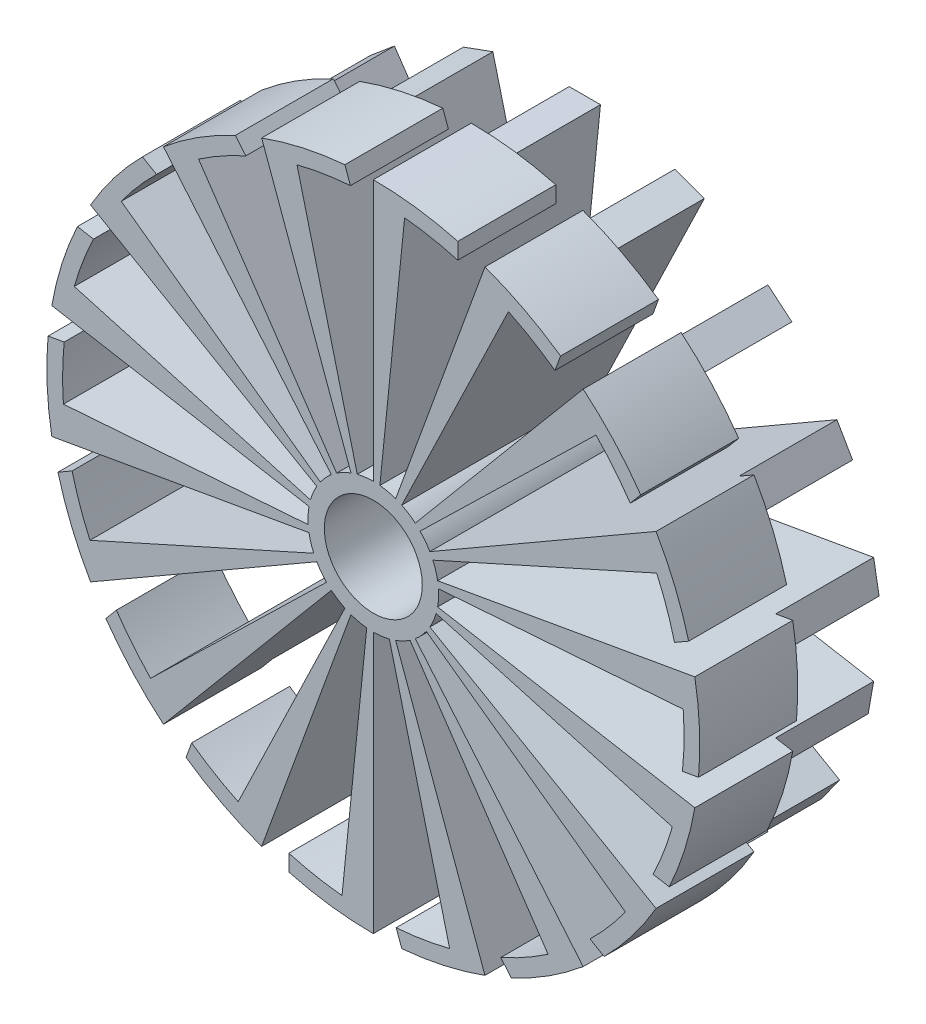
from build123d import *

# Parameters (mm, degrees)
SCHIZZO1_R                      = 20
SCHIZZO1_R_2                    = 15
ESTRUSIONE_ESTRUSIONE1_DEPTH    = 30
ESTRUSIONE_ESTRUSIONE1_2_DEPTH  = 30
ESTRUSIONE_ESTRUSIONE1_3_DEPTH  = 30
ESTRUSIONE_ESTRUSIONE1_4_DEPTH  = 30
ESTRUSIONE_ESTRUSIONE1_5_DEPTH  = 30
ESTRUSIONE_ESTRUSIONE1_6_DEPTH  = 30
ESTRUSIONE_ESTRUSIONE1_7_DEPTH  = 30
ESTRUSIONE_ESTRUSIONE1_8_DEPTH  = 30
ESTRUSIONE_ESTRUSIONE1_9_DEPTH  = 30
ESTRUSIONE_ESTRUSIONE1_10_DEPTH = 30
ESTRUSIONE_ESTRUSIONE1_11_DEPTH = 30
ESTRUSIONE_ESTRUSIONE1_12_DEPTH = 30
ESTRUSIONE_ESTRUSIONE1_13_DEPTH = 30
ESTRUSIONE_ESTRUSIONE1_14_DEPTH = 30
ESTRUSIONE_ESTRUSIONE1_15_DEPTH = 30
ESTRUSIONE_ESTRUSIONE1_16_DEPTH = 30
ESTRUSIONE_ESTRUSIONE1_17_DEPTH = 30
ESTRUSIONE_ESTRUSIONE1_18_DEPTH = 30
ESTRUSIONE_ESTRUSIONE1_19_DEPTH = 30
SCHIZZO1_12_R                   = 15
SCHIZZO1_12_R_2                 = 5
ESTRUSIONE_ESTRUSIONE8_DEPTH    = 30
ESTRUSIONE_ESTRUSIONE9_DEPTH    = 30
ESTRUSIONE_ESTRUSIONE9_2_DEPTH  = 30
ESTRUSIONE_ESTRUSIONE9_3_DEPTH  = 30
ESTRUSIONE_ESTRUSIONE9_4_DEPTH  = 30
ESTRUSIONE_ESTRUSIONE9_5_DEPTH  = 30
ESTRUSIONE_ESTRUSIONE9_6_DEPTH  = 30
ESTRUSIONE_ESTRUSIONE9_7_DEPTH  = 30
ESTRUSIONE_ESTRUSIONE9_8_DEPTH  = 30
ESTRUSIONE_ESTRUSIONE9_9_DEPTH  = 30
ESTRUSIONE_ESTRUSIONE9_10_DEPTH = 30
ESTRUSIONE_ESTRUSIONE9_11_DEPTH = 30
ESTRUSIONE_ESTRUSIONE9_12_DEPTH = 30
ESTRUSIONE_ESTRUSIONE9_13_DEPTH = 30
ESTRUSIONE_ESTRUSIONE9_14_DEPTH = 30
ESTRUSIONE_ESTRUSIONE9_15_DEPTH = 30
ESTRUSIONE_ESTRUSIONE9_16_DEPTH = 30
ESTRUSIONE_ESTRUSIONE9_17_DEPTH = 30
ESTRUSIONE_ESTRUSIONE9_18_DEPTH = 30
SCHIZZO1_14_R                   = 15
ESTRUSIONE_ESTRUSIONE10_DEPTH   = 30
SCHIZZO1_16_R                   = 20
SCHIZZO1_16_R_2                 = 15
ESTRUSIONE_ESTRUSIONE11_DEPTH   = 30
ESTRUSIONE_ESTRUSIONE12_DEPTH   = 30


with BuildPart() as part:
    # Schizzo1 → Estrusione-Estrusione1 (new body)
    with BuildSketch(Plane.XY):
        Circle(SCHIZZO1_R)
        Circle(SCHIZZO1_R_2, mode=Mode.SUBTRACT)
    extrude(amount=ESTRUSIONE_ESTRUSIONE1_DEPTH)



with BuildPart() as body_2:
    # Schizzo1 → Estrusione-Estrusione1 2 (new body)
    with BuildSketch(Plane.XY):
        with BuildLine():
            Line((0, 100), (0, 94.695431044))
            Line((0, 94.695431044), (9.583815163, 94.695431044))
            ThreePointArc((9.583815163, 94.695431044), (17.80059648, 93.499801811), (25.88190451, 91.592582629))
            Line((25.88190451, 91.592582629), (25.88190451, 96.592582629))
            ThreePointArc((25.88190451, 96.592582629), (13.052619222, 99.144486137), (0, 100))
        make_face()
    extrude(amount=ESTRUSIONE_ESTRUSIONE1_2_DEPTH)


with BuildPart() as body_3:
    # Schizzo1 → Estrusione-Estrusione1 3 (new body)
    with BuildSketch(Plane.XY):
        with BuildLine():
            Line((-32.387744898, 88.984597774), (-23.38190451, 92.26245561))
            ThreePointArc((-23.38190451, 92.26245561), (-15.251726458, 93.949236366), (-7.005473558, 94.921006705))
            Line((-7.005473558, 94.921006705), (-8.715574275, 99.619469809))
            ThreePointArc((-8.715574275, 99.619469809), (-21.643961394, 97.629600712), (-34.202014333, 93.969262079))
            Line((-34.202014333, 93.969262079), (-32.387744898, 88.984597774))
        make_face()
    extrude(amount=ESTRUSIONE_ESTRUSIONE1_3_DEPTH)


with BuildPart() as body_4:
    # Schizzo1 → Estrusione-Estrusione1 4 (new body)
    with BuildSketch(Plane.XY):
        with BuildLine():
            Line((34.202014333, 93.969262079), (32.387744898, 88.984597774))
            Line((32.387744898, 88.984597774), (41.393585286, 85.706739939))
            ThreePointArc((41.393585286, 85.706739939), (48.705904774, 81.772911247), (55.647542918, 77.216741325))
            Line((55.647542918, 77.216741325), (57.357643635, 81.915204429))
            ThreePointArc((57.357643635, 81.915204429), (46.174861324, 88.701083318), (34.202014333, 93.969262079))
        make_face()
    extrude(amount=ESTRUSIONE_ESTRUSIONE1_4_DEPTH)


with BuildPart() as body_5:
    # Schizzo1 → Estrusione-Estrusione1 5 (new body)
    with BuildSketch(Plane.XY):
        with BuildLine():
            Line((-60.869049769, 72.54090874), (-53.52742142, 78.70126638))
            ThreePointArc((-53.52742142, 78.70126638), (-46.464466094, 83.067006473), (-39.047888126, 86.800556488))
            Line((-39.047888126, 86.800556488), (-42.261826174, 90.630778704))
            ThreePointArc((-42.261826174, 90.630778704), (-53.729960835, 84.339144581), (-64.278760969, 76.604444312))
            Line((-64.278760969, 76.604444312), (-60.869049769, 72.54090874))
        make_face()
    extrude(amount=ESTRUSIONE_ESTRUSIONE1_5_DEPTH)


with BuildPart() as body_6:
    # Schizzo1 → Estrusione-Estrusione1 6 (new body)
    with BuildSketch(Plane.XY):
        with BuildLine():
            Line((64.278760969, 76.604444312), (60.869049769, 72.54090874))
            Line((60.869049769, 72.54090874), (68.210678119, 66.3805511))
            ThreePointArc((68.210678119, 66.3805511), (73.73656213, 60.183000747), (78.70126638, 53.52742142))
            Line((78.70126638, 53.52742142), (81.915204429, 57.357643635))
            ThreePointArc((81.915204429, 57.357643635), (73.727733681, 67.559020762), (64.278760969, 76.604444312))
        make_face()
    extrude(amount=ESTRUSIONE_ESTRUSIONE1_6_DEPTH)


with BuildPart() as body_7:
    # Schizzo1 → Estrusione-Estrusione1 7 (new body)
    with BuildSketch(Plane.XY):
        with BuildLine():
            Line((-82.008648907, 47.347715522), (-77.216741325, 55.647542918))
            ThreePointArc((-77.216741325, 55.647542918), (-72.072905377, 62.16566966), (-66.3805511, 68.210678119))
            Line((-66.3805511, 68.210678119), (-70.710678119, 70.710678119))
            ThreePointArc((-70.710678119, 70.710678119), (-79.335334029, 60.876142901), (-86.602540378, 50))
            Line((-86.602540378, 50), (-82.008648907, 47.347715522))
        make_face()
    extrude(amount=ESTRUSIONE_ESTRUSIONE1_7_DEPTH)


with BuildPart() as body_8:
    # Schizzo1 → Estrusione-Estrusione1 8 (new body)
    with BuildSketch(Plane.XY):
        with BuildLine():
            Line((86.602540378, 50), (82.008648907, 47.347715522))
            Line((82.008648907, 47.347715522), (86.800556488, 39.047888126))
            ThreePointArc((86.800556488, 39.047888126), (89.873501857, 31.334132151), (92.26245561, 23.38190451))
            Line((92.26245561, 23.38190451), (96.592582629, 25.88190451))
            ThreePointArc((96.592582629, 25.88190451), (92.387953251, 38.268343237), (86.602540378, 50))
        make_face()
    extrude(amount=ESTRUSIONE_ESTRUSIONE1_8_DEPTH)


with BuildPart() as body_9:
    # Schizzo1 → Estrusione-Estrusione1 9 (new body)
    with BuildSketch(Plane.XY):
        with BuildLine():
            Line((-93.256794667, 16.443689034), (-91.592582629, 25.88190451))
            ThreePointArc((-91.592582629, 25.88190451), (-88.988288588, 33.766235619), (-85.706739939, 41.393585286))
            Line((-85.706739939, 41.393585286), (-90.630778704, 42.261826174))
            ThreePointArc((-90.630778704, 42.261826174), (-95.371695075, 30.07057995), (-98.480775301, 17.364817767))
            Line((-98.480775301, 17.364817767), (-93.256794667, 16.443689034))
        make_face()
    extrude(amount=ESTRUSIONE_ESTRUSIONE1_9_DEPTH)


with BuildPart() as body_10:
    # Schizzo1 → Estrusione-Estrusione1 10 (new body)
    with BuildSketch(Plane.XY):
        with BuildLine():
            Line((98.480775301, 17.364817767), (93.256794667, 16.443689034))
            Line((93.256794667, 16.443689034), (94.921006705, 7.005473558))
            ThreePointArc((94.921006705, 7.005473558), (95.170370869, -1.294095226), (94.695431044, -9.583815163))
            Line((94.695431044, -9.583815163), (99.619469809, -8.715574275))
            ThreePointArc((99.619469809, -8.715574275), (99.904822158, 4.361938737), (98.480775301, 17.364817767))
        make_face()
    extrude(amount=ESTRUSIONE_ESTRUSIONE1_10_DEPTH)


with BuildPart() as body_11:
    # Schizzo1 → Estrusione-Estrusione1 11 (new body)
    with BuildSketch(Plane.XY):
        with BuildLine():
            Line((-93.256794667, -16.443689034), (-94.921006705, -7.005473558))
            ThreePointArc((-94.921006705, -7.005473558), (-95.170370869, 1.294095226), (-94.695431044, 9.583815163))
            Line((-94.695431044, 9.583815163), (-99.619469809, 8.715574275))
            ThreePointArc((-99.619469809, 8.715574275), (-99.904822158, -4.361938737), (-98.480775301, -17.364817767))
            Line((-98.480775301, -17.364817767), (-93.256794667, -16.443689034))
        make_face()
    extrude(amount=ESTRUSIONE_ESTRUSIONE1_11_DEPTH)


with BuildPart() as body_12:
    # Schizzo1 → Estrusione-Estrusione1 12 (new body)
    with BuildSketch(Plane.XY):
        with BuildLine():
            Line((98.480775301, -17.364817767), (93.256794667, -16.443689034))
            Line((93.256794667, -16.443689034), (91.592582629, -25.88190451))
            ThreePointArc((91.592582629, -25.88190451), (88.988288588, -33.766235619), (85.706739939, -41.393585286))
            Line((85.706739939, -41.393585286), (90.630778704, -42.261826174))
            ThreePointArc((90.630778704, -42.261826174), (95.371695075, -30.07057995), (98.480775301, -17.364817767))
        make_face()
    extrude(amount=ESTRUSIONE_ESTRUSIONE1_12_DEPTH)


with BuildPart() as body_13:
    # Schizzo1 → Estrusione-Estrusione1 13 (new body)
    with BuildSketch(Plane.XY):
        with BuildLine():
            Line((-82.008648907, -47.347715522), (-86.800556488, -39.047888126))
            ThreePointArc((-86.800556488, -39.047888126), (-89.873501857, -31.334132151), (-92.26245561, -23.38190451))
            Line((-92.26245561, -23.38190451), (-96.592582629, -25.88190451))
            ThreePointArc((-96.592582629, -25.88190451), (-92.387953251, -38.268343237), (-86.602540378, -50))
            Line((-86.602540378, -50), (-82.008648907, -47.347715522))
        make_face()
    extrude(amount=ESTRUSIONE_ESTRUSIONE1_13_DEPTH)


with BuildPart() as body_14:
    # Schizzo1 → Estrusione-Estrusione1 14 (new body)
    with BuildSketch(Plane.XY):
        with BuildLine():
            Line((86.602540378, -50), (82.848647318, -47.832688831))
            Line((82.848647318, -47.832688831), (77.216741325, -55.647542918))
            ThreePointArc((77.216741325, -55.647542918), (72.072905377, -62.16566966), (66.3805511, -68.210678119))
            Line((66.3805511, -68.210678119), (70.710678119, -70.710678119))
            ThreePointArc((70.710678119, -70.710678119), (79.335334029, -60.876142901), (86.602540378, -50))
        make_face()
    extrude(amount=ESTRUSIONE_ESTRUSIONE1_14_DEPTH)


with BuildPart() as body_15:
    # Schizzo1 → Estrusione-Estrusione1 15 (new body)
    with BuildSketch(Plane.XY):
        with BuildLine():
            Line((-60.869049769, -72.54090874), (-68.210678119, -66.3805511))
            ThreePointArc((-68.210678119, -66.3805511), (-73.73656213, -60.183000747), (-78.70126638, -53.52742142))
            Line((-78.70126638, -53.52742142), (-81.915204429, -57.357643635))
            ThreePointArc((-81.915204429, -57.357643635), (-73.727733681, -67.559020762), (-64.278760969, -76.604444312))
            Line((-64.278760969, -76.604444312), (-60.869049769, -72.54090874))
        make_face()
    extrude(amount=ESTRUSIONE_ESTRUSIONE1_15_DEPTH)


with BuildPart() as body_16:
    # Schizzo1 → Estrusione-Estrusione1 16 (new body)
    with BuildSketch(Plane.XY):
        with BuildLine():
            Line((64.278760969, -76.604444312), (60.869049769, -72.54090874))
            Line((60.869049769, -72.54090874), (53.52742142, -78.70126638))
            ThreePointArc((53.52742142, -78.70126638), (46.464466094, -83.067006473), (39.047888126, -86.800556488))
            Line((39.047888126, -86.800556488), (42.261826174, -90.630778704))
            ThreePointArc((42.261826174, -90.630778704), (53.729960835, -84.339144581), (64.278760969, -76.604444312))
        make_face()
    extrude(amount=ESTRUSIONE_ESTRUSIONE1_16_DEPTH)


with BuildPart() as body_17:
    # Schizzo1 → Estrusione-Estrusione1 17 (new body)
    with BuildSketch(Plane.XY):
        with BuildLine():
            Line((-32.387744898, -88.984597774), (-41.393585286, -85.706739939))
            ThreePointArc((-41.393585286, -85.706739939), (-48.705904774, -81.772911247), (-55.647542918, -77.216741325))
            Line((-55.647542918, -77.216741325), (-57.357643635, -81.915204429))
            ThreePointArc((-57.357643635, -81.915204429), (-46.174861324, -88.701083318), (-34.202014333, -93.969262079))
            Line((-34.202014333, -93.969262079), (-32.387744898, -88.984597774))
        make_face()
    extrude(amount=ESTRUSIONE_ESTRUSIONE1_17_DEPTH)


with BuildPart() as body_18:
    # Schizzo1 → Estrusione-Estrusione1 18 (new body)
    with BuildSketch(Plane.XY):
        with BuildLine():
            Line((34.202014333, -93.969262079), (32.387744898, -88.984597774))
            Line((32.387744898, -88.984597774), (23.38190451, -92.26245561))
            ThreePointArc((23.38190451, -92.26245561), (15.251726458, -93.949236366), (7.005473558, -94.921006705))
            Line((7.005473558, -94.921006705), (8.715574275, -99.619469809))
            ThreePointArc((8.715574275, -99.619469809), (21.643961394, -97.629600712), (34.202014333, -93.969262079))
        make_face()
    extrude(amount=ESTRUSIONE_ESTRUSIONE1_18_DEPTH)


with BuildPart() as body_19:
    # Schizzo1 → Estrusione-Estrusione1 19 (new body)
    with BuildSketch(Plane.XY):
        with BuildLine():
            Line((0, -94.695431044), (-9.583815163, -94.695431044))
            ThreePointArc((-9.583815163, -94.695431044), (-17.80059648, -93.499801811), (-25.88190451, -91.592582629))
            Line((-25.88190451, -91.592582629), (-25.88190451, -96.592582629))
            ThreePointArc((-25.88190451, -96.592582629), (-13.052619222, -99.144486137), (0, -100))
            Line((0, -100), (0, -94.695431044))
        make_face()
    extrude(amount=ESTRUSIONE_ESTRUSIONE1_19_DEPTH)


with BuildPart() as body_20:
    # Schizzo1_12 → Estrusione-Estrusione8 (new body)
    with BuildSketch(Plane.XY):
        Circle(SCHIZZO1_12_R)
        Circle(SCHIZZO1_12_R_2, mode=Mode.SUBTRACT)
    extrude(amount=-ESTRUSIONE_ESTRUSIONE8_DEPTH)



with BuildPart() as body_21:
    # Schizzo1_13 → Estrusione-Estrusione9 (new body)
    with BuildSketch(Plane.XY):
        with BuildLine():
            Line((0, 94.695431044), (0, 20))
            ThreePointArc((0, 20), (1.008205442, 19.97457188), (2.013847207, 19.898352179))
            Line((2.013847207, 19.898352179), (9.583815163, 94.695431044))
            Line((9.583815163, 94.695431044), (0, 94.695431044))
        make_face()
    extrude(amount=-ESTRUSIONE_ESTRUSIONE9_DEPTH)


with BuildPart() as body_22:
    # Schizzo1_13 → Estrusione-Estrusione9 2 (new body)
    with BuildSketch(Plane.XY):
        with BuildLine():
            ThreePointArc((-6.840402867, 18.793852416), (-5.884302723, 19.114784369), (-4.913239904, 19.387111018))
            Line((-4.913239904, 19.387111018), (-23.38190451, 92.26245561))
            Line((-23.38190451, 92.26245561), (-32.387744898, 88.984597774))
            Line((-32.387744898, 88.984597774), (-6.840402867, 18.793852416))
        make_face()
    extrude(amount=-ESTRUSIONE_ESTRUSIONE9_2_DEPTH)


with BuildPart() as body_23:
    # Schizzo1_13 → Estrusione-Estrusione9 3 (new body)
    with BuildSketch(Plane.XY):
        with BuildLine():
            Line((32.387744898, 88.984597774), (6.840402867, 18.793852416))
            ThreePointArc((6.840402867, 18.793852416), (7.779109151, 18.425131229), (8.698034624, 18.009558398))
            Line((8.698034624, 18.009558398), (41.393585286, 85.706739939))
            Line((41.393585286, 85.706739939), (32.387744898, 88.984597774))
        make_face()
    extrude(amount=-ESTRUSIONE_ESTRUSIONE9_3_DEPTH)


with BuildPart() as body_24:
    # Schizzo1_13 → Estrusione-Estrusione9 4 (new body)
    with BuildSketch(Plane.XY):
        with BuildLine():
            ThreePointArc((-12.855752194, 15.320888862), (-12.067077137, 15.949471758), (-11.247717771, 16.537498146))
            Line((-11.247717771, 16.537498146), (-53.52742142, 78.70126638))
            Line((-53.52742142, 78.70126638), (-60.869049769, 72.54090874))
            Line((-60.869049769, 72.54090874), (-12.855752194, 15.320888862))
        make_face()
    extrude(amount=-ESTRUSIONE_ESTRUSIONE9_4_DEPTH)


with BuildPart() as body_25:
    # Schizzo1_13 → Estrusione-Estrusione9 5 (new body)
    with BuildSketch(Plane.XY):
        with BuildLine():
            Line((60.869049769, 72.54090874), (12.855752194, 15.320888862))
            ThreePointArc((12.855752194, 15.320888862), (13.61173749, 14.653347826), (14.333110696, 13.948546081))
            Line((14.333110696, 13.948546081), (68.210678119, 66.3805511))
            Line((68.210678119, 66.3805511), (60.869049769, 72.54090874))
        make_face()
    extrude(amount=-ESTRUSIONE_ESTRUSIONE9_5_DEPTH)


with BuildPart() as body_26:
    # Schizzo1_13 → Estrusione-Estrusione9 6 (new body)
    with BuildSketch(Plane.XY):
        with BuildLine():
            ThreePointArc((-17.320508076, 10), (-16.794383957, 10.860417465), (-16.225554877, 11.69321893))
            Line((-16.225554877, 11.69321893), (-77.216741325, 55.647542918))
            Line((-77.216741325, 55.647542918), (-82.008648907, 47.347715522))
            Line((-82.008648907, 47.347715522), (-17.320508076, 10))
        make_face()
    extrude(amount=-ESTRUSIONE_ESTRUSIONE9_6_DEPTH)


with BuildPart() as body_27:
    # Schizzo1_13 → Estrusione-Estrusione9 7 (new body)
    with BuildSketch(Plane.XY):
        with BuildLine():
            Line((82.008648907, 47.347715522), (17.320508076, 10))
            ThreePointArc((17.320508076, 10), (17.802589399, 9.114154415), (18.239402084, 8.205133249))
            Line((18.239402084, 8.205133249), (86.800556488, 39.047888126))
            Line((86.800556488, 39.047888126), (82.008648907, 47.347715522))
        make_face()
    extrude(amount=-ESTRUSIONE_ESTRUSIONE9_7_DEPTH)


with BuildPart() as body_28:
    # Schizzo1_13 → Estrusione-Estrusione9 8 (new body)
    with BuildSketch(Plane.XY):
        with BuildLine():
            ThreePointArc((-19.69615506, 3.472963553), (-19.496040213, 4.461436543), (-19.2463506, 5.438564937))
            Line((-19.2463506, 5.438564937), (-91.592582629, 25.88190451))
            Line((-91.592582629, 25.88190451), (-93.256794667, 16.443689034))
            Line((-93.256794667, 16.443689034), (-19.69615506, 3.472963553))
        make_face()
    extrude(amount=-ESTRUSIONE_ESTRUSIONE9_8_DEPTH)


with BuildPart() as body_29:
    # Schizzo1_13 → Estrusione-Estrusione9 9 (new body)
    with BuildSketch(Plane.XY):
        with BuildLine():
            Line((93.256794667, 16.443689034), (19.69615506, 3.472963553))
            ThreePointArc((19.69615506, 3.472963553), (19.846186288, 2.475659471), (19.945752395, 1.472060251))
            Line((19.945752395, 1.472060251), (94.921006705, 7.005473558))
            Line((94.921006705, 7.005473558), (93.256794667, 16.443689034))
        make_face()
    extrude(amount=-ESTRUSIONE_ESTRUSIONE9_9_DEPTH)


with BuildPart() as body_30:
    # Schizzo1_13 → Estrusione-Estrusione9 10 (new body)
    with BuildSketch(Plane.XY):
        with BuildLine():
            ThreePointArc((-19.69615506, -3.472963553), (-19.846186288, -2.475659471), (-19.945752395, -1.472060251))
            Line((-19.945752395, -1.472060251), (-94.921006705, -7.005473558))
            Line((-94.921006705, -7.005473558), (-93.256794667, -16.443689034))
            Line((-93.256794667, -16.443689034), (-19.69615506, -3.472963553))
        make_face()
    extrude(amount=-ESTRUSIONE_ESTRUSIONE9_10_DEPTH)


with BuildPart() as body_31:
    # Schizzo1_13 → Estrusione-Estrusione9 11 (new body)
    with BuildSketch(Plane.XY):
        with BuildLine():
            Line((93.256794667, -16.443689034), (19.69615506, -3.472963553))
            ThreePointArc((19.69615506, -3.472963553), (19.496040213, -4.461436543), (19.2463506, -5.438564937))
            Line((19.2463506, -5.438564937), (91.592582629, -25.88190451))
            Line((91.592582629, -25.88190451), (93.256794667, -16.443689034))
        make_face()
    extrude(amount=-ESTRUSIONE_ESTRUSIONE9_11_DEPTH)


with BuildPart() as body_32:
    # Schizzo1_13 → Estrusione-Estrusione9 12 (new body)
    with BuildSketch(Plane.XY):
        with BuildLine():
            ThreePointArc((-17.320508076, -10), (-17.802589399, -9.114154415), (-18.239402084, -8.205133249))
            Line((-18.239402084, -8.205133249), (-86.800556488, -39.047888126))
            Line((-86.800556488, -39.047888126), (-82.008648907, -47.347715522))
            Line((-82.008648907, -47.347715522), (-17.320508076, -10))
        make_face()
    extrude(amount=-ESTRUSIONE_ESTRUSIONE9_12_DEPTH)


with BuildPart() as body_33:
    # Schizzo1_13 → Estrusione-Estrusione9 13 (new body)
    with BuildSketch(Plane.XY):
        with BuildLine():
            Line((82.848647318, -47.832688831), (17.320508076, -10))
            ThreePointArc((17.320508076, -10), (16.794383957, -10.860417465), (16.225554877, -11.69321893))
            Line((16.225554877, -11.69321893), (77.216741325, -55.647542918))
            Line((77.216741325, -55.647542918), (82.848647318, -47.832688831))
        make_face()
    extrude(amount=-ESTRUSIONE_ESTRUSIONE9_13_DEPTH)


with BuildPart() as body_34:
    # Schizzo1_13 → Estrusione-Estrusione9 14 (new body)
    with BuildSketch(Plane.XY):
        with BuildLine():
            ThreePointArc((-12.855752194, -15.320888862), (-13.61173749, -14.653347826), (-14.333110696, -13.948546081))
            Line((-14.333110696, -13.948546081), (-68.210678119, -66.3805511))
            Line((-68.210678119, -66.3805511), (-60.869049769, -72.54090874))
            Line((-60.869049769, -72.54090874), (-12.855752194, -15.320888862))
        make_face()
    extrude(amount=-ESTRUSIONE_ESTRUSIONE9_14_DEPTH)


with BuildPart() as body_35:
    # Schizzo1_13 → Estrusione-Estrusione9 15 (new body)
    with BuildSketch(Plane.XY):
        with BuildLine():
            Line((60.869049769, -72.54090874), (12.855752194, -15.320888862))
            ThreePointArc((12.855752194, -15.320888862), (12.067077137, -15.949471758), (11.247717771, -16.537498146))
            Line((11.247717771, -16.537498146), (53.52742142, -78.70126638))
            Line((53.52742142, -78.70126638), (60.869049769, -72.54090874))
        make_face()
    extrude(amount=-ESTRUSIONE_ESTRUSIONE9_15_DEPTH)


with BuildPart() as body_36:
    # Schizzo1_13 → Estrusione-Estrusione9 16 (new body)
    with BuildSketch(Plane.XY):
        with BuildLine():
            ThreePointArc((-6.840402867, -18.793852416), (-7.779109151, -18.425131229), (-8.698034624, -18.009558398))
            Line((-8.698034624, -18.009558398), (-41.393585286, -85.706739939))
            Line((-41.393585286, -85.706739939), (-32.387744898, -88.984597774))
            Line((-32.387744898, -88.984597774), (-6.840402867, -18.793852416))
        make_face()
    extrude(amount=-ESTRUSIONE_ESTRUSIONE9_16_DEPTH)


with BuildPart() as body_37:
    # Schizzo1_13 → Estrusione-Estrusione9 17 (new body)
    with BuildSketch(Plane.XY):
        with BuildLine():
            Line((32.387744898, -88.984597774), (6.840402867, -18.793852416))
            ThreePointArc((6.840402867, -18.793852416), (5.884302723, -19.114784369), (4.913239904, -19.387111018))
            Line((4.913239904, -19.387111018), (23.38190451, -92.26245561))
            Line((23.38190451, -92.26245561), (32.387744898, -88.984597774))
        make_face()
    extrude(amount=-ESTRUSIONE_ESTRUSIONE9_17_DEPTH)


with BuildPart() as body_38:
    # Schizzo1_13 → Estrusione-Estrusione9 18 (new body)
    with BuildSketch(Plane.XY):
        with BuildLine():
            ThreePointArc((0, -20), (-1.008205442, -19.97457188), (-2.013847207, -19.898352179))
            Line((-2.013847207, -19.898352179), (-9.583815163, -94.695431044))
            Line((-9.583815163, -94.695431044), (0, -94.695431044))
            Line((0, -94.695431044), (0, -20))
        make_face()
    extrude(amount=-ESTRUSIONE_ESTRUSIONE9_18_DEPTH)


with BuildPart() as body_20_1:
    add(body_20.part)

    add(body_22.part)  # Estrusione-Estrusione10 merges body 22

    add(body_23.part)  # Estrusione-Estrusione10 merges body 23

    add(body_24.part)  # Estrusione-Estrusione10 merges body 24

    add(body_25.part)  # Estrusione-Estrusione10 merges body 25

    add(body_26.part)  # Estrusione-Estrusione10 merges body 26

    add(body_27.part)  # Estrusione-Estrusione10 merges body 27

    add(body_28.part)  # Estrusione-Estrusione10 merges body 28

    add(body_29.part)  # Estrusione-Estrusione10 merges body 29

    add(body_30.part)  # Estrusione-Estrusione10 merges body 30

    add(body_31.part)  # Estrusione-Estrusione10 merges body 31

    add(body_32.part)  # Estrusione-Estrusione10 merges body 32

    add(body_33.part)  # Estrusione-Estrusione10 merges body 33

    add(body_34.part)  # Estrusione-Estrusione10 merges body 34

    add(body_35.part)  # Estrusione-Estrusione10 merges body 35

    add(body_36.part)  # Estrusione-Estrusione10 merges body 36

    add(body_37.part)  # Estrusione-Estrusione10 merges body 37
    # Schizzo1_14 → Estrusione-Estrusione10 (add)
    with BuildSketch(Plane.XY):
        with BuildLine():
            ThreePointArc((2.013847207, 19.898352179), (1.008205442, 19.97457188), (0, 20))
            ThreePointArc((0, 20), (-2.475659471, 19.846186288), (-4.913239904, 19.387111018))
            ThreePointArc((-4.913239904, 19.387111018), (-5.884302723, 19.114784369), (-6.840402867, 18.793852416))
            ThreePointArc((-6.840402867, 18.793852416), (-9.114154415, 17.802589399), (-11.247717771, 16.537498146))
            ThreePointArc((-11.247717771, 16.537498146), (-12.067077137, 15.949471758), (-12.855752194, 15.320888862))
            ThreePointArc((-12.855752194, 15.320888862), (-14.653347826, 13.61173749), (-16.225554877, 11.69321893))
            ThreePointArc((-16.225554877, 11.69321893), (-16.794383957, 10.860417465), (-17.320508076, 10))
            ThreePointArc((-17.320508076, 10), (-18.425131229, 7.779109151), (-19.2463506, 5.438564937))
            ThreePointArc((-19.2463506, 5.438564937), (-19.496040213, 4.461436543), (-19.69615506, 3.472963553))
            ThreePointArc((-19.69615506, 3.472963553), (-19.97457188, 1.008205442), (-19.945752395, -1.472060251))
            ThreePointArc((-19.945752395, -1.472060251), (-19.846186288, -2.475659471), (-19.69615506, -3.472963553))
            ThreePointArc((-19.69615506, -3.472963553), (-19.114784369, -5.884302723), (-18.239402084, -8.205133249))
            ThreePointArc((-18.239402084, -8.205133249), (-17.802589399, -9.114154415), (-17.320508076, -10))
            ThreePointArc((-17.320508076, -10), (-15.949471758, -12.067077137), (-14.333110696, -13.948546081))
            ThreePointArc((-14.333110696, -13.948546081), (-13.61173749, -14.653347826), (-12.855752194, -15.320888862))
            ThreePointArc((-12.855752194, -15.320888862), (-10.860417465, -16.794383957), (-8.698034624, -18.009558398))
            ThreePointArc((-8.698034624, -18.009558398), (-7.779109151, -18.425131229), (-6.840402867, -18.793852416))
            ThreePointArc((-6.840402867, -18.793852416), (-4.461436543, -19.496040213), (-2.013847207, -19.898352179))
            ThreePointArc((-2.013847207, -19.898352179), (-1.008205442, -19.97457188), (0, -20))
            ThreePointArc((0, -20), (2.475659471, -19.846186288), (4.913239904, -19.387111018))
            ThreePointArc((4.913239904, -19.387111018), (5.884302723, -19.114784369), (6.840402867, -18.793852416))
            ThreePointArc((6.840402867, -18.793852416), (9.114154415, -17.802589399), (11.247717771, -16.537498146))
            ThreePointArc((11.247717771, -16.537498146), (12.067077137, -15.949471758), (12.855752194, -15.320888862))
            ThreePointArc((12.855752194, -15.320888862), (14.653347826, -13.61173749), (16.225554877, -11.69321893))
            ThreePointArc((16.225554877, -11.69321893), (16.794383957, -10.860417465), (17.320508076, -10))
            ThreePointArc((17.320508076, -10), (18.425131229, -7.779109151), (19.2463506, -5.438564937))
            ThreePointArc((19.2463506, -5.438564937), (19.496040213, -4.461436543), (19.69615506, -3.472963553))
            ThreePointArc((19.69615506, -3.472963553), (19.923893962, -1.743114855), (20, 0))
            ThreePointArc((20, 0), (19.986433498, 0.736529732), (19.945752395, 1.472060251))
            ThreePointArc((19.945752395, 1.472060251), (19.846186288, 2.475659471), (19.69615506, 3.472963553))
            ThreePointArc((19.69615506, 3.472963553), (19.114784369, 5.884302723), (18.239402084, 8.205133249))
            ThreePointArc((18.239402084, 8.205133249), (17.802589399, 9.114154415), (17.320508076, 10))
            ThreePointArc((17.320508076, 10), (15.949471758, 12.067077137), (14.333110696, 13.948546081))
            ThreePointArc((14.333110696, 13.948546081), (13.61173749, 14.653347826), (12.855752194, 15.320888862))
            ThreePointArc((12.855752194, 15.320888862), (10.860417465, 16.794383957), (8.698034624, 18.009558398))
            ThreePointArc((8.698034624, 18.009558398), (7.779109151, 18.425131229), (6.840402867, 18.793852416))
            ThreePointArc((6.840402867, 18.793852416), (4.461436543, 19.496040213), (2.013847207, 19.898352179))
        make_face()
        Circle(SCHIZZO1_14_R, mode=Mode.SUBTRACT)
    extrude(amount=-ESTRUSIONE_ESTRUSIONE10_DEPTH)


with BuildPart() as body_23_2:
    # Schizzo1_16 → Estrusione-Estrusione11 (new body)
    with BuildSketch(Plane.XY):
        Circle(SCHIZZO1_16_R)
        Circle(SCHIZZO1_16_R_2, mode=Mode.SUBTRACT)
    extrude(amount=ESTRUSIONE_ESTRUSIONE11_DEPTH)


with BuildPart() as part_1:
    add(part.part)

    add(body_2.part)  # Estrusione-Estrusione12 merges body 2

    add(body_3.part)  # Estrusione-Estrusione12 merges body 3

    add(body_4.part)  # Estrusione-Estrusione12 merges body 4

    add(body_5.part)  # Estrusione-Estrusione12 merges body 5

    add(body_6.part)  # Estrusione-Estrusione12 merges body 6

    add(body_7.part)  # Estrusione-Estrusione12 merges body 7

    add(body_8.part)  # Estrusione-Estrusione12 merges body 8

    add(body_9.part)  # Estrusione-Estrusione12 merges body 9

    add(body_10.part)  # Estrusione-Estrusione12 merges body 10

    add(body_11.part)  # Estrusione-Estrusione12 merges body 11

    add(body_12.part)  # Estrusione-Estrusione12 merges body 12

    add(body_13.part)  # Estrusione-Estrusione12 merges body 13

    add(body_14.part)  # Estrusione-Estrusione12 merges body 14

    add(body_15.part)  # Estrusione-Estrusione12 merges body 15

    add(body_16.part)  # Estrusione-Estrusione12 merges body 16

    add(body_17.part)  # Estrusione-Estrusione12 merges body 17

    add(body_18.part)  # Estrusione-Estrusione12 merges body 18

    add(body_19.part)  # Estrusione-Estrusione12 merges body 19

    add(body_20_1.part)  # Estrusione-Estrusione12 merges body 20

    add(body_21.part)  # Estrusione-Estrusione12 merges body 21

    add(body_38.part)  # Estrusione-Estrusione12 merges body 38

    add(body_23_2.part)  # Estrusione-Estrusione12 merges body 23 2
    # Schizzo1_17 → Estrusione-Estrusione12 (add)
    with BuildSketch(Plane.XY):
        with BuildLine():
            ThreePointArc((-6.840402867, 18.793852416), (-5.884302723, 19.114784369), (-4.913239904, 19.387111018))
            Line((-4.913239904, 19.387111018), (-23.38190451, 92.26245561))
            Line((-23.38190451, 92.26245561), (-32.387744898, 88.984597774))
            Line((-32.387744898, 88.984597774), (-6.840402867, 18.793852416))
        make_face()
        with BuildLine():
            Line((0, 94.695431044), (0, 20))
            ThreePointArc((0, 20), (1.008205442, 19.97457188), (2.013847207, 19.898352179))
            Line((2.013847207, 19.898352179), (9.583815163, 94.695431044))
            Line((9.583815163, 94.695431044), (0, 94.695431044))
        make_face()
        with BuildLine():
            Line((32.387744898, 88.984597774), (6.840402867, 18.793852416))
            ThreePointArc((6.840402867, 18.793852416), (7.779109151, 18.425131229), (8.698034624, 18.009558398))
            Line((8.698034624, 18.009558398), (41.393585286, 85.706739939))
            Line((41.393585286, 85.706739939), (32.387744898, 88.984597774))
        make_face()
        with BuildLine():
            Line((60.869049769, 72.54090874), (12.855752194, 15.320888862))
            ThreePointArc((12.855752194, 15.320888862), (13.61173749, 14.653347826), (14.333110696, 13.948546081))
            Line((14.333110696, 13.948546081), (68.210678119, 66.3805511))
            Line((68.210678119, 66.3805511), (60.869049769, 72.54090874))
        make_face()
        with BuildLine():
            Line((82.008648907, 47.347715522), (17.320508076, 10))
            ThreePointArc((17.320508076, 10), (17.802589399, 9.114154415), (18.239402084, 8.205133249))
            Line((18.239402084, 8.205133249), (86.800556488, 39.047888126))
            Line((86.800556488, 39.047888126), (82.008648907, 47.347715522))
        make_face()
        with BuildLine():
            Line((93.256794667, 16.443689034), (19.69615506, 3.472963553))
            ThreePointArc((19.69615506, 3.472963553), (19.846186288, 2.475659471), (19.945752395, 1.472060251))
            Line((19.945752395, 1.472060251), (94.921006705, 7.005473558))
            Line((94.921006705, 7.005473558), (93.256794667, 16.443689034))
        make_face()
        with BuildLine():
            Line((93.256794667, -16.443689034), (19.69615506, -3.472963553))
            ThreePointArc((19.69615506, -3.472963553), (19.496040213, -4.461436543), (19.2463506, -5.438564937))
            Line((19.2463506, -5.438564937), (91.592582629, -25.88190451))
            Line((91.592582629, -25.88190451), (93.256794667, -16.443689034))
        make_face()
        with BuildLine():
            Line((82.848647318, -47.832688831), (17.320508076, -10))
            ThreePointArc((17.320508076, -10), (16.794383957, -10.860417465), (16.225554877, -11.69321893))
            Line((16.225554877, -11.69321893), (77.216741325, -55.647542918))
            Line((77.216741325, -55.647542918), (82.848647318, -47.832688831))
        make_face()
        with BuildLine():
            Line((60.869049769, -72.54090874), (12.855752194, -15.320888862))
            ThreePointArc((12.855752194, -15.320888862), (12.067077137, -15.949471758), (11.247717771, -16.537498146))
            Line((11.247717771, -16.537498146), (53.52742142, -78.70126638))
            Line((53.52742142, -78.70126638), (60.869049769, -72.54090874))
        make_face()
        with BuildLine():
            Line((32.387744898, -88.984597774), (6.840402867, -18.793852416))
            ThreePointArc((6.840402867, -18.793852416), (5.884302723, -19.114784369), (4.913239904, -19.387111018))
            Line((4.913239904, -19.387111018), (23.38190451, -92.26245561))
            Line((23.38190451, -92.26245561), (32.387744898, -88.984597774))
        make_face()
        with BuildLine():
            ThreePointArc((0, -20), (-1.008205442, -19.97457188), (-2.013847207, -19.898352179))
            Line((-2.013847207, -19.898352179), (-9.583815163, -94.695431044))
            Line((-9.583815163, -94.695431044), (0, -94.695431044))
            Line((0, -94.695431044), (0, -20))
        make_face()
        with BuildLine():
            ThreePointArc((-6.840402867, -18.793852416), (-7.779109151, -18.425131229), (-8.698034624, -18.009558398))
            Line((-8.698034624, -18.009558398), (-41.393585286, -85.706739939))
            Line((-41.393585286, -85.706739939), (-32.387744898, -88.984597774))
            Line((-32.387744898, -88.984597774), (-6.840402867, -18.793852416))
        make_face()
        with BuildLine():
            ThreePointArc((-12.855752194, -15.320888862), (-13.61173749, -14.653347826), (-14.333110696, -13.948546081))
            Line((-14.333110696, -13.948546081), (-68.210678119, -66.3805511))
            Line((-68.210678119, -66.3805511), (-60.869049769, -72.54090874))
            Line((-60.869049769, -72.54090874), (-12.855752194, -15.320888862))
        make_face()
        with BuildLine():
            ThreePointArc((-17.320508076, -10), (-17.802589399, -9.114154415), (-18.239402084, -8.205133249))
            Line((-18.239402084, -8.205133249), (-86.800556488, -39.047888126))
            Line((-86.800556488, -39.047888126), (-82.008648907, -47.347715522))
            Line((-82.008648907, -47.347715522), (-17.320508076, -10))
        make_face()
        with BuildLine():
            ThreePointArc((-19.69615506, -3.472963553), (-19.846186288, -2.475659471), (-19.945752395, -1.472060251))
            Line((-19.945752395, -1.472060251), (-94.921006705, -7.005473558))
            Line((-94.921006705, -7.005473558), (-93.256794667, -16.443689034))
            Line((-93.256794667, -16.443689034), (-19.69615506, -3.472963553))
        make_face()
        with BuildLine():
            ThreePointArc((-19.69615506, 3.472963553), (-19.496040213, 4.461436543), (-19.2463506, 5.438564937))
            Line((-19.2463506, 5.438564937), (-91.592582629, 25.88190451))
            Line((-91.592582629, 25.88190451), (-93.256794667, 16.443689034))
            Line((-93.256794667, 16.443689034), (-19.69615506, 3.472963553))
        make_face()
        with BuildLine():
            ThreePointArc((-17.320508076, 10), (-16.794383957, 10.860417465), (-16.225554877, 11.69321893))
            Line((-16.225554877, 11.69321893), (-77.216741325, 55.647542918))
            Line((-77.216741325, 55.647542918), (-82.008648907, 47.347715522))
            Line((-82.008648907, 47.347715522), (-17.320508076, 10))
        make_face()
        with BuildLine():
            ThreePointArc((-12.855752194, 15.320888862), (-12.067077137, 15.949471758), (-11.247717771, 16.537498146))
            Line((-11.247717771, 16.537498146), (-53.52742142, 78.70126638))
            Line((-53.52742142, 78.70126638), (-60.869049769, 72.54090874))
            Line((-60.869049769, 72.54090874), (-12.855752194, 15.320888862))
        make_face()
    extrude(amount=ESTRUSIONE_ESTRUSIONE12_DEPTH)


solid = part_1.part
